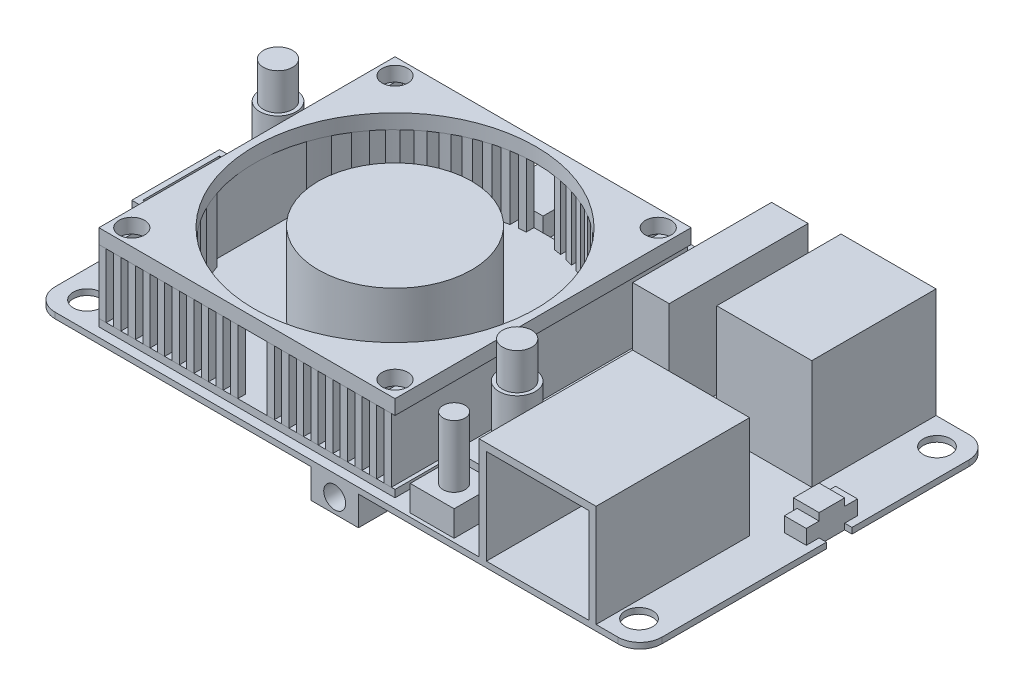
from build123d import *

# Parameters (mm, degrees)
SKETCH1_W                      = 83
SKETCH1_H                      = 48
SKETCH1_R                      = 1.875
BOSS_EXTRUDE1_DEPTH            = 0.8
FILLET1_R                      = 3
BOSS_EXTRUDE2_START            = 11
SKETCH2_R                      = 1.75
SKETCH2_R_2                    = 19.25
BOSS_EXTRUDE2_DEPTH            = 2
SKETCH2_3_W                    = 13
SKETCH2_3_H                    = 17
BOSS_EXTRUDE3_DEPTH            = 15
SKETCH2_4_W                    = 16
SKETCH2_4_H                    = 21
BOSS_EXTRUDE4_DEPTH            = 14
SKETCH2_5_W                    = 5
SKETCH2_5_H                    = 19
BOSS_EXTRUDE5_DEPTH            = 14
SKETCH2_6_R                    = 1.5
BOSS_EXTRUDE6_DEPTH            = 12
SKETCH2_7_W                    = 6
SKETCH2_7_H                    = 6
SKETCH2_7_R                    = 1.5
BOSS_EXTRUDE7_DEPTH            = 3.5
SKETCH2_8_W                    = 7
SKETCH2_8_H                    = 4.25
SKETCH2_8_H_2                  = 0.75
BOSS_EXTRUDE8_DEPTH            = 2.5
SKETCH2_9_W                    = 6.5
SKETCH2_9_H                    = 6.25
SKETCH2_9_H_2                  = 0.75
BOSS_EXTRUDE9_DEPTH            = 3
SKETCH2_10_W                   = 5
SKETCH2_10_H                   = 7.5
BOSS_EXTRUDE10_DEPTH           = 3.5
BOSS_EXTRUDE11_START           = 1.25
BOSS_EXTRUDE11_DEPTH           = 1
BOSS_EXTRUDE12_START           = 2.25
SKETCH2_12_R                   = 2.5
SKETCH2_12_R_2                 = 2
BOSS_EXTRUDE12_DEPTH           = 9
BOSS_EXTRUDE14_START           = 2.25
SKETCH2_13_R                   = 2
BOSS_EXTRUDE14_DEPTH           = 14
BOSS_EXTRUDE15_DEPTH           = 3
SKETCH2_15_W                   = 1
SKETCH2_15_H                   = 3.5
CUT_EXTRUDE1_DEPTH             = 3
SKETCH2_16_W                   = 3
SKETCH2_16_H                   = 1.75
BOSS_EXTRUDE16_DEPTH           = 2
SKETCH2_17_W                   = 2
SKETCH2_17_H                   = 1.75
BOSS_EXTRUDE17_DEPTH           = 2
BOSS_EXTRUDE18_DEPTH           = 6
SKETCH2_19_W                   = 5.06789321
SKETCH2_19_H                   = 12
BOSS_EXTRUDE19_DEPTH           = 5.5
CHAMFER1_SIZE                  = 1
BOSS_EXTRUDE23_DEPTH           = 8.75
BOSS_EXTRUDE23_2_DEPTH         = 8.75
BOSS_EXTRUDE23_3_DEPTH         = 8.75
BOSS_EXTRUDE23_4_DEPTH         = 8.75
BOSS_EXTRUDE23_5_DEPTH         = 8.75
BOSS_EXTRUDE23_6_DEPTH         = 8.75
BOSS_EXTRUDE23_7_DEPTH         = 8.75
BOSS_EXTRUDE23_8_DEPTH         = 8.75
BOSS_EXTRUDE23_9_DEPTH         = 8.75
BOSS_EXTRUDE23_10_DEPTH        = 8.75
BOSS_EXTRUDE23_11_DEPTH        = 8.75
BOSS_EXTRUDE23_12_DEPTH        = 8.75
BOSS_EXTRUDE23_13_DEPTH        = 8.75
BOSS_EXTRUDE23_14_DEPTH        = 8.75
BOSS_EXTRUDE23_15_DEPTH        = 8.75
BOSS_EXTRUDE23_16_DEPTH        = 8.75
BOSS_EXTRUDE23_17_DEPTH        = 8.75
BOSS_EXTRUDE23_18_DEPTH        = 8.75
BOSS_EXTRUDE23_19_DEPTH        = 8.75
BOSS_EXTRUDE23_20_DEPTH        = 8.75
BOSS_EXTRUDE23_21_DEPTH        = 8.75
BOSS_EXTRUDE23_22_DEPTH        = 8.75
BOSS_EXTRUDE23_23_DEPTH        = 8.75
BOSS_EXTRUDE23_24_DEPTH        = 8.75
BOSS_EXTRUDE23_25_DEPTH        = 8.75
BOSS_EXTRUDE23_26_DEPTH        = 8.75
BOSS_EXTRUDE23_27_DEPTH        = 8.75
BOSS_EXTRUDE23_28_DEPTH        = 8.75
BOSS_EXTRUDE23_29_DEPTH        = 8.75
BOSS_EXTRUDE23_30_DEPTH        = 8.75
BOSS_EXTRUDE23_31_DEPTH        = 8.75
BOSS_EXTRUDE23_32_DEPTH        = 8.75
BOSS_EXTRUDE23_33_DEPTH        = 8.75
BOSS_EXTRUDE23_34_DEPTH        = 8.75
BOSS_EXTRUDE23_35_DEPTH        = 8.75
BOSS_EXTRUDE23_36_DEPTH        = 8.75
BOSS_EXTRUDE24_START           = 2.25
SKETCH2_20_R                   = 10.5
BOSS_EXTRUDE24_DEPTH           = 11
SKETCH4_W                      = 4.5
SKETCH4_H                      = 8.5
BOSS_EXTRUDE25_DEPTH           = 4.5
SKETCH4_3_W                    = 11
SKETCH4_3_H                    = 5
BOSS_EXTRUDE26_DEPTH           = 3
SKETCH4_4_W                    = 11
SKETCH4_4_H                    = 13
BOSS_EXTRUDE27_DEPTH           = 2.5
SKETCH4_5_W                    = 13
SKETCH4_5_H                    = 18
SKETCH4_5_W_2                  = 11
SKETCH4_5_H_2                  = 13
BOSS_EXTRUDE28_DEPTH           = 2
SKETCH4_6_W                    = 6.5
SKETCH4_6_H                    = 13
BOSS_EXTRUDE29_DEPTH           = 4
SKETCH4_7_R                    = 1.5
BOSS_EXTRUDE30_DEPTH           = 4
BOSS_EXTRUDE30_DRAFT           = 5
BOSS_EXTRUDE30_PROFILE_2_DEPTH = 4
BOSS_EXTRUDE30_PROFILE_2_DRAFT = 5
SKETCH4_8_R                    = 1.5
BOSS_EXTRUDE31_DEPTH           = 2
BOSS_EXTRUDE31_DRAFT           = 5
BOSS_EXTRUDE31_PROFILE_2_DEPTH = 2
BOSS_EXTRUDE31_PROFILE_2_DRAFT = 5
SKETCH5_W                      = 14
SKETCH5_H                      = 13
CUT_EXTRUDE2_DEPTH             = 19
SKETCH6_W                      = 11
SKETCH6_H                      = 6
SKETCH6_W_2                    = 4
SKETCH6_H_2                    = 13.5
CUT_EXTRUDE3_DEPTH             = 15
SKETCH7_R                      = 1.5
CUT_EXTRUDE4_DEPTH             = 11
CUT_EXTRUDE5_DEPTH             = 5.5


with BuildPart() as part:
    # Sketch1 → Boss-Extrude1 (new body)
    with BuildSketch(Plane(origin=(0, 0, 0), x_dir=(1, 0, 0), z_dir=(0, 1, 0))):
        with Locations((-41.5, 24)):
            Rectangle(SKETCH1_W, SKETCH1_H)
        with Locations(Location((-79.25, 44.375, 0), (0, 0, 270))):
            Circle(SKETCH1_R, mode=Mode.SUBTRACT)
        with Locations(Location((-79.25, 3.625, 0), (0, 0, 270))):
            Circle(SKETCH1_R, mode=Mode.SUBTRACT)
        with Locations(Location((-3.75, 44.375, 0), (0, 0, 270))):
            Circle(SKETCH1_R, mode=Mode.SUBTRACT)
        with Locations(Location((-3.75, 3.625, 0), (0, 0, 270))):
            Circle(SKETCH1_R, mode=Mode.SUBTRACT)
    extrude(amount=BOSS_EXTRUDE1_DEPTH)

    # Fillet1
    fillet1_edges = [part.edges().sort_by_distance(p)[0] for p in [
        (0, 0.4, 0),
        (-83, 0.4, 0),
        (-83, 0.4, -48),
        (0, 0.4, -48),
    ]]
    fillet(fillet1_edges, radius=FILLET1_R)

    # Sketch2_3 → Boss-Extrude3 (add)
    with BuildSketch(Plane(origin=(0, 0.8, 0), x_dir=(1, 0, 0), z_dir=(0, 1, 0))):
        with Locations((-14, 39.5)):
            Rectangle(SKETCH2_3_W, SKETCH2_3_H)
    extrude(amount=BOSS_EXTRUDE3_DEPTH)

    # Sketch2_4 → Boss-Extrude4 (add)
    with BuildSketch(Plane(origin=(0, 0.8, 0), x_dir=(1, 0, 0), z_dir=(0, 1, 0))):
        with Locations((-14, 10.5)):
            Rectangle(SKETCH2_4_W, SKETCH2_4_H)
    extrude(amount=BOSS_EXTRUDE4_DEPTH)

    # Sketch2_5 → Boss-Extrude5 (add)
    with BuildSketch(Plane(origin=(0, 0.8, 0), x_dir=(1, 0, 0), z_dir=(0, 1, 0))):
        with Locations((-27.5, 38.5)):
            Rectangle(SKETCH2_5_W, SKETCH2_5_H)
    extrude(amount=BOSS_EXTRUDE5_DEPTH)

    # Sketch2_6 → Boss-Extrude6 (add)
    with BuildSketch(Plane(origin=(0, 0.8, 0), x_dir=(1, 0, 0), z_dir=(0, 1, 0))):
        with Locations(Location((-28.917074657, 3.5, 0), (0, 0, 90))):
            Circle(SKETCH2_6_R)
    extrude(amount=BOSS_EXTRUDE6_DEPTH)

    # Sketch2_7 → Boss-Extrude7 (add)
    with BuildSketch(Plane(origin=(0, 0.8, 0), x_dir=(1, 0, 0), z_dir=(0, 1, 0))):
        with Locations((-28.917074657, 3.5)):
            Rectangle(SKETCH2_7_W, SKETCH2_7_H)
        with Locations(Location((-28.917074657, 3.5, 0), (0, 0, 270))):
            Circle(SKETCH2_7_R, mode=Mode.SUBTRACT)
    extrude(amount=BOSS_EXTRUDE7_DEPTH)

    # Sketch2_8 → Boss-Extrude8 (add)
    with BuildSketch(Plane(origin=(0, 0.8, 0), x_dir=(1, 0, 0), z_dir=(0, 1, 0))):
        with Locations((-72, 45.875)):
            Rectangle(SKETCH2_8_W, SKETCH2_8_H)
        with Locations((-72, 48.375)):
            Rectangle(SKETCH2_8_W, SKETCH2_8_H_2)
    extrude(amount=BOSS_EXTRUDE8_DEPTH)

    # Sketch2_9 → Boss-Extrude9 (add)
    with BuildSketch(Plane(origin=(0, 0.8, 0), x_dir=(1, 0, 0), z_dir=(0, 1, 0))):
        with Locations((-58.25, 44.875)):
            Rectangle(SKETCH2_9_W, SKETCH2_9_H)
        with Locations((-58.25, 48.375)):
            Rectangle(SKETCH2_9_W, SKETCH2_9_H_2)
    extrude(amount=BOSS_EXTRUDE9_DEPTH)

    # Sketch2_10 → Boss-Extrude10 (add)
    with BuildSketch(Plane(origin=(0, 0.8, 0), x_dir=(1, 0, 0), z_dir=(0, 1, 0))):
        with Locations((-39.5, 44.25)):
            Rectangle(SKETCH2_10_W, SKETCH2_10_H)
    extrude(amount=BOSS_EXTRUDE10_DEPTH)

    # Sketch2_11 → Boss-Extrude11 (add)
    with BuildSketch(Plane(origin=(0, 0.8, 0), x_dir=(1, 0, 0), z_dir=(0, 1, 0)).offset(BOSS_EXTRUDE11_START)):
        with BuildLine():
            Line((-74, 40.5), (-74, 32.5))
            Line((-74, 32.5), (-78.5, 32.5))
            ThreePointArc((-78.5, 32.5), (-82, 29), (-78.5, 25.5))
            Line((-78.5, 25.5), (-74, 25.5))
            Line((-74, 25.5), (-74, 0))
            Line((-74, 0), (-33.5, 0))
            Line((-33.5, 0), (-33.5, 8.705630347))
            Line((-33.5, 8.705630347), (-29, 8.705630347))
            ThreePointArc((-29, 8.705630347), (-25.5, 12.205630347), (-29, 15.705630347))
            Line((-29, 15.705630347), (-33.5, 15.705630347))
            Line((-33.5, 15.705630347), (-33.5, 40.5))
            Line((-33.5, 40.5), (-74, 40.5))
        make_face()
    extrude(amount=BOSS_EXTRUDE11_DEPTH)

    # Sketch2_12 → Boss-Extrude12 (add)
    with BuildSketch(Plane(origin=(0, 0.8, 0), x_dir=(1, 0, 0), z_dir=(0, 1, 0)).offset(BOSS_EXTRUDE12_START)):
        with Locations(Location((-78.5, 29, 0), (0, 0, 270))):
            Circle(SKETCH2_12_R)
        with Locations(Location((-78.5, 29, 0), (0, 0, 270))):
            Circle(SKETCH2_12_R_2, mode=Mode.SUBTRACT)
        with Locations(Location((-29, 12.205630347, 0), (0, 0, 270))):
            Circle(SKETCH2_12_R)
        with Locations(Location((-29, 12.205630347, 0), (0, 0, 270))):
            Circle(SKETCH2_12_R_2, mode=Mode.SUBTRACT)
    extrude(amount=BOSS_EXTRUDE12_DEPTH)

    # Sketch2_13 → Boss-Extrude14 (add)
    with BuildSketch(Plane(origin=(0, 0.8, 0), x_dir=(1, 0, 0), z_dir=(0, 1, 0)).offset(BOSS_EXTRUDE14_START)):
        with Locations(Location((-78.5, 29, 0), (0, 0, 270))):
            Circle(SKETCH2_13_R)
        with Locations(Location((-29, 12.205630347, 0), (0, 0, 270))):
            Circle(SKETCH2_13_R)
    extrude(amount=BOSS_EXTRUDE14_DEPTH)

    # Sketch2_14 → Boss-Extrude15 (add)
    with BuildSketch(Plane(origin=(0, 0.8, 0), x_dir=(1, 0, 0), z_dir=(0, 1, 0))):
        Polygon((-1, 25.5), (-1, 29), (-4, 29), (-4.5, 29), (-4.5, 25.5), (-4, 25.5), align=None)
    extrude(amount=BOSS_EXTRUDE15_DEPTH)

    # Sketch2_15 → Cut-Extrude1 (cut)
    with BuildSketch(Plane(origin=(0, 0.8, 0), x_dir=(1, 0, 0), z_dir=(0, 1, 0))):
        with Locations((-0.5, 27.25)):
            Rectangle(SKETCH2_15_W, SKETCH2_15_H)
    extrude(amount=-CUT_EXTRUDE1_DEPTH, mode=Mode.SUBTRACT)

    # Sketch2_16 → Boss-Extrude16 (add)
    with BuildSketch(Plane(origin=(0, 0.8, 0), x_dir=(1, 0, 0), z_dir=(0, 1, 0))):
        with Locations((-2.5, 29.875)):
            Rectangle(SKETCH2_16_W, SKETCH2_16_H)
        with Locations((-2.5, 24.625)):
            Rectangle(SKETCH2_16_W, SKETCH2_16_H)
    extrude(amount=BOSS_EXTRUDE16_DEPTH)

    # Sketch2_17 → Boss-Extrude17 (add)
    with BuildSketch(Plane(origin=(0, 0.8, 0), x_dir=(1, 0, 0), z_dir=(0, 1, 0))):
        Polygon((-27, 22), (-27, 20.25), (-29, 20.25), (-29, 27.25), (-27, 27.25), (-27, 25.5), (-26.5, 25.5), (-26.5, 22), align=None)
        with Locations((-28, 21.125)):
            Rectangle(SKETCH2_17_W, SKETCH2_17_H)
        with Locations((-28, 26.375)):
            Rectangle(SKETCH2_17_W, SKETCH2_17_H)
    extrude(amount=BOSS_EXTRUDE17_DEPTH)

    # Sketch2_18 → Boss-Extrude18 (add)
    with BuildSketch(Plane(origin=(0, 0.8, 0), x_dir=(1, 0, 0), z_dir=(0, 1, 0))):
        Polygon((-27, 25.5), (-29, 25.5), (-29, 22), (-27, 22), (-26.5, 22), (-26.5, 25.5), align=None)
    extrude(amount=BOSS_EXTRUDE18_DEPTH)

    # Sketch2_19 → Boss-Extrude19 (add)
    with BuildSketch(Plane(origin=(0, 0.8, 0), x_dir=(1, 0, 0), z_dir=(0, 1, 0))):
        with Locations((-79.966053395, 19)):
            Rectangle(SKETCH2_19_W, SKETCH2_19_H)
    extrude(amount=BOSS_EXTRUDE19_DEPTH)

    # Chamfer1
    chamfer1_edges = [part.edges().sort_by_distance(p)[0] for p in [
        (-77.43210679, 3.55, -25),
    ]]
    chamfer(chamfer1_edges, length=CHAMFER1_SIZE)

    # Sketch2_20 → Boss-Extrude24 (add)
    with BuildSketch(Plane(origin=(0, 0.8, 0), x_dir=(1, 0, 0), z_dir=(0, 1, 0)).offset(BOSS_EXTRUDE24_START)):
        with Locations(Location((-53.75, 20.25, 0), (0, 0, 270))):
            Circle(SKETCH2_20_R)
    extrude(amount=BOSS_EXTRUDE24_DEPTH)

    # Sketch4 → Boss-Extrude25 (add)
    with BuildSketch(Plane.XZ):
        with Locations((-80.25, -36.75)):
            Rectangle(SKETCH4_W, SKETCH4_H)
    extrude(amount=BOSS_EXTRUDE25_DEPTH)

    # Sketch4_3 → Boss-Extrude26 (add)
    with BuildSketch(Plane.XZ):
        with Locations((-69, -12.5)):
            Rectangle(SKETCH4_3_W, SKETCH4_3_H)
    extrude(amount=BOSS_EXTRUDE26_DEPTH)

    # Sketch4_4 → Boss-Extrude27 (add)
    with BuildSketch(Plane.XZ):
        with Locations((-56.5, -10)):
            Rectangle(SKETCH4_4_W, SKETCH4_4_H)
    extrude(amount=BOSS_EXTRUDE27_DEPTH)

    # Sketch4_5 → Boss-Extrude28 (add)
    with BuildSketch(Plane.XZ):
        with Locations((-56.5, -11)):
            Rectangle(SKETCH4_5_W, SKETCH4_5_H)
        with Locations((-56.5, -10)):
            Rectangle(SKETCH4_5_W_2, SKETCH4_5_H_2, mode=Mode.SUBTRACT)
    extrude(amount=BOSS_EXTRUDE28_DEPTH)

    # Sketch4_6 → Boss-Extrude29 (add)
    with BuildSketch(Plane.XZ):
        with Locations((-41.75, -6.5)):
            Rectangle(SKETCH4_6_W, SKETCH4_6_H)
    extrude(amount=BOSS_EXTRUDE29_DEPTH)


with BuildPart() as body_2:
    # Sketch2 → Boss-Extrude2 (new body)
    with BuildSketch(Plane(origin=(0, 0.8, 0), x_dir=(1, 0, 0), z_dir=(0, 1, 0)).offset(BOSS_EXTRUDE2_START)):
        Polygon((-42, 40.5), (-74, 40.5), (-74, 32.5), (-74, 25.5), (-74, 0), (-33.5, 0), (-33.5, 8.705630347), (-33.5, 15.705630347), (-33.5, 40.5), (-37, 40.5), align=None)
        with Locations(Location((-71.75, 2.25, 0), (0, 0, 270))):
            Circle(SKETCH2_R, mode=Mode.SUBTRACT)
        with Locations(Location((-53.75, 20.25, 0), (0, 0, 270))):
            Circle(SKETCH2_R_2, mode=Mode.SUBTRACT)
        with Locations(Location((-35.75, 2.25, 0), (0, 0, 270))):
            Circle(SKETCH2_R, mode=Mode.SUBTRACT)
        with Locations(Location((-71.75, 38.25, 0), (0, 0, 270))):
            Circle(SKETCH2_R, mode=Mode.SUBTRACT)
        with Locations(Location((-35.75, 38.25, 0), (0, 0, 270))):
            Circle(SKETCH2_R, mode=Mode.SUBTRACT)
    extrude(amount=BOSS_EXTRUDE2_DEPTH)


with BuildPart() as body_3:
    # Sketch3 → Boss-Extrude23 (new body)
    with BuildSketch(Plane(origin=(0, 3.05, 0), x_dir=(1, 0, 0), z_dir=(0, 1, 0))):
        Polygon((-74, 40.5), (-74, 32.5), (-74, 25.5), (-74, 0), (-73, 0), (-73, 20.25), (-73, 25.5), (-73, 32.5), (-73, 40.5), align=None)
    extrude(amount=BOSS_EXTRUDE23_DEPTH)


with BuildPart() as body_4:
    # Sketch3 → Boss-Extrude23 2 (new body)
    with BuildSketch(Plane(origin=(0, 3.05, 0), x_dir=(1, 0, 0), z_dir=(0, 1, 0))):
        with BuildLine():
            Line((-72, 14.126275643), (-72, 0))
            Line((-72, 0), (-71, 0))
            Line((-71, 0), (-71, 11.705996255))
            ThreePointArc((-71, 11.705996255), (-71.541203952, 12.899111488), (-72, 14.126275643))
        make_face()
    extrude(amount=BOSS_EXTRUDE23_2_DEPTH)


with BuildPart() as body_5:
    # Sketch3 → Boss-Extrude23 3 (new body)
    with BuildSketch(Plane(origin=(0, 3.05, 0), x_dir=(1, 0, 0), z_dir=(0, 1, 0))):
        with BuildLine():
            Line((-70, 9.93011628), (-70, 0))
            Line((-70, 0), (-69, 0))
            Line((-69, 0), (-69, 8.502659876))
            ThreePointArc((-69, 8.502659876), (-69.516163387, 9.205064869), (-70, 9.93011628))
        make_face()
    extrude(amount=BOSS_EXTRUDE23_3_DEPTH)


with BuildPart() as body_6:
    # Sketch3 → Boss-Extrude23 4 (new body)
    with BuildSketch(Plane(origin=(0, 3.05, 0), x_dir=(1, 0, 0), z_dir=(0, 1, 0))):
        with BuildLine():
            Line((-68, 7.307820894), (-68, 0))
            Line((-68, 0), (-67, 0))
            Line((-67, 0), (-67, 6.285759956))
            ThreePointArc((-67, 6.285759956), (-67.509493164, 6.787502169), (-68, 7.307820894))
        make_face()
    extrude(amount=BOSS_EXTRUDE23_4_DEPTH)


with BuildPart() as body_7:
    # Sketch3 → Boss-Extrude23 5 (new body)
    with BuildSketch(Plane(origin=(0, 3.05, 0), x_dir=(1, 0, 0), z_dir=(0, 1, 0))):
        with BuildLine():
            Line((-66, 5.400757595), (-66, 0))
            Line((-66, 0), (-65, 0))
            Line((-65, 0), (-65, 4.629500648))
            ThreePointArc((-65, 4.629500648), (-65.506326353, 5.006926469), (-66, 5.400757595))
        make_face()
    extrude(amount=BOSS_EXTRUDE23_5_DEPTH)


with BuildPart() as body_8:
    # Sketch3 → Boss-Extrude23 6 (new body)
    with BuildSketch(Plane(origin=(0, 3.05, 0), x_dir=(1, 0, 0), z_dir=(0, 1, 0))):
        with BuildLine():
            Line((-64, 3.955829263), (-64, 0))
            Line((-64, 0), (-63, 0))
            Line((-63, 0), (-63, 3.368056984))
            ThreePointArc((-63, 3.368056984), (-63.504428177, 3.654409292), (-64, 3.955829263))
        make_face()
    extrude(amount=BOSS_EXTRUDE23_6_DEPTH)


with BuildPart() as body_9:
    # Sketch3 → Boss-Extrude23 7 (new body)
    with BuildSketch(Plane(origin=(0, 3.05, 0), x_dir=(1, 0, 0), z_dir=(0, 1, 0))):
        with BuildLine():
            Line((-62, 2.857472869), (-62, 0))
            Line((-62, 0), (-61, 0))
            Line((-61, 0), (-61, 2.4174455))
            ThreePointArc((-61, 2.4174455), (-61.50312234, 2.630363398), (-62, 2.857472869))
        make_face()
    extrude(amount=BOSS_EXTRUDE23_7_DEPTH)


with BuildPart() as body_10:
    # Sketch3 → Boss-Extrude23 8 (new body)
    with BuildSketch(Plane(origin=(0, 3.05, 0), x_dir=(1, 0, 0), z_dir=(0, 1, 0))):
        with BuildLine():
            Line((-60, 2.042858544), (-60, 0))
            Line((-60, 0), (-59, 0))
            Line((-59, 0), (-59, 1.729740823))
            ThreePointArc((-59, 1.729740823), (-59.502130968, 1.879494037), (-60, 2.042858544))
        make_face()
    extrude(amount=BOSS_EXTRUDE23_8_DEPTH)


with BuildPart() as body_11:
    # Sketch3 → Boss-Extrude23 9 (new body)
    with BuildSketch(Plane(origin=(0, 3.05, 0), x_dir=(1, 0, 0), z_dir=(0, 1, 0))):
        with BuildLine():
            Line((-58, 1.475016644), (-58, 0))
            Line((-58, 0), (-57, 0))
            Line((-57, 0), (-57, 1.276334039))
            ThreePointArc((-57, 1.276334039), (-57.501315595, 1.36905375), (-58, 1.475016644))
        make_face()
    extrude(amount=BOSS_EXTRUDE23_9_DEPTH)


with BuildPart() as body_12:
    # Sketch3 → Boss-Extrude23 10 (new body)
    with BuildSketch(Plane(origin=(0, 3.05, 0), x_dir=(1, 0, 0), z_dir=(0, 1, 0))):
        with BuildLine():
            Line((-56, 1.131945706), (-56, 0))
            Line((-56, 0), (-55, 0))
            Line((-55, 0), (-55, 1.040627288))
            ThreePointArc((-55, 1.040627288), (-55.500595545, 1.079764862), (-56, 1.131945706))
        make_face()
    extrude(amount=BOSS_EXTRUDE23_10_DEPTH)


with BuildPart() as body_13:
    # Sketch3 → Boss-Extrude23 11 (new body)
    with BuildSketch(Plane(origin=(0, 3.05, 0), x_dir=(1, 0, 0), z_dir=(0, 1, 0))):
        with BuildLine():
            Line((-71, 40.5), (-72, 40.5))
            Line((-72, 40.5), (-72, 32.5))
            Line((-72, 32.5), (-72, 26.373724357))
            ThreePointArc((-72, 26.373724357), (-71.541203952, 27.600888512), (-71, 28.794003745))
            Line((-71, 28.794003745), (-71, 32.5))
            Line((-71, 32.5), (-71, 40.5))
        make_face()
    extrude(amount=BOSS_EXTRUDE23_11_DEPTH)


with BuildPart() as body_14:
    # Sketch3 → Boss-Extrude23 12 (new body)
    with BuildSketch(Plane(origin=(0, 3.05, 0), x_dir=(1, 0, 0), z_dir=(0, 1, 0))):
        with BuildLine():
            Line((-69, 40.5), (-70, 40.5))
            Line((-70, 40.5), (-70, 32.5))
            Line((-70, 32.5), (-70, 30.56988372))
            ThreePointArc((-70, 30.56988372), (-69.516163387, 31.294935131), (-69, 31.997340124))
            Line((-69, 31.997340124), (-69, 32.5))
            Line((-69, 32.5), (-69, 40.5))
        make_face()
    extrude(amount=BOSS_EXTRUDE23_12_DEPTH)


with BuildPart() as body_15:
    # Sketch3 → Boss-Extrude23 13 (new body)
    with BuildSketch(Plane(origin=(0, 3.05, 0), x_dir=(1, 0, 0), z_dir=(0, 1, 0))):
        with BuildLine():
            Line((-67, 40.5), (-68, 40.5))
            Line((-68, 40.5), (-68, 33.192179106))
            ThreePointArc((-68, 33.192179106), (-67.509493164, 33.712497831), (-67, 34.214240044))
            Line((-67, 34.214240044), (-67, 40.5))
        make_face()
    extrude(amount=BOSS_EXTRUDE23_13_DEPTH)


with BuildPart() as body_16:
    # Sketch3 → Boss-Extrude23 14 (new body)
    with BuildSketch(Plane(origin=(0, 3.05, 0), x_dir=(1, 0, 0), z_dir=(0, 1, 0))):
        with BuildLine():
            Line((-65, 40.5), (-66, 40.5))
            Line((-66, 40.5), (-66, 35.099242405))
            ThreePointArc((-66, 35.099242405), (-65.506326353, 35.493073531), (-65, 35.870499352))
            Line((-65, 35.870499352), (-65, 40.5))
        make_face()
    extrude(amount=BOSS_EXTRUDE23_14_DEPTH)


with BuildPart() as body_17:
    # Sketch3 → Boss-Extrude23 15 (new body)
    with BuildSketch(Plane(origin=(0, 3.05, 0), x_dir=(1, 0, 0), z_dir=(0, 1, 0))):
        with BuildLine():
            Line((-63, 40.5), (-64, 40.5))
            Line((-64, 40.5), (-64, 36.544170737))
            ThreePointArc((-64, 36.544170737), (-63.504428177, 36.845590708), (-63, 37.131943016))
            Line((-63, 37.131943016), (-63, 40.5))
        make_face()
    extrude(amount=BOSS_EXTRUDE23_15_DEPTH)


with BuildPart() as body_18:
    # Sketch3 → Boss-Extrude23 16 (new body)
    with BuildSketch(Plane(origin=(0, 3.05, 0), x_dir=(1, 0, 0), z_dir=(0, 1, 0))):
        with BuildLine():
            Line((-61, 40.5), (-62, 40.5))
            Line((-62, 40.5), (-62, 37.642527131))
            ThreePointArc((-62, 37.642527131), (-61.50312234, 37.869636602), (-61, 38.0825545))
            Line((-61, 38.0825545), (-61, 40.5))
        make_face()
    extrude(amount=BOSS_EXTRUDE23_16_DEPTH)


with BuildPart() as body_19:
    # Sketch3 → Boss-Extrude23 17 (new body)
    with BuildSketch(Plane(origin=(0, 3.05, 0), x_dir=(1, 0, 0), z_dir=(0, 1, 0))):
        with BuildLine():
            Line((-59, 40.5), (-60, 40.5))
            Line((-60, 40.5), (-60, 38.457141456))
            ThreePointArc((-60, 38.457141456), (-59.502130968, 38.620505963), (-59, 38.770259177))
            Line((-59, 38.770259177), (-59, 40.5))
        make_face()
    extrude(amount=BOSS_EXTRUDE23_17_DEPTH)


with BuildPart() as body_20:
    # Sketch3 → Boss-Extrude23 18 (new body)
    with BuildSketch(Plane(origin=(0, 3.05, 0), x_dir=(1, 0, 0), z_dir=(0, 1, 0))):
        with BuildLine():
            Line((-57, 40.5), (-58, 40.5))
            Line((-58, 40.5), (-58, 39.024983356))
            ThreePointArc((-58, 39.024983356), (-57.501315595, 39.13094625), (-57, 39.223665961))
            Line((-57, 39.223665961), (-57, 40.5))
        make_face()
    extrude(amount=BOSS_EXTRUDE23_18_DEPTH)


with BuildPart() as body_21:
    # Sketch3 → Boss-Extrude23 19 (new body)
    with BuildSketch(Plane(origin=(0, 3.05, 0), x_dir=(1, 0, 0), z_dir=(0, 1, 0))):
        with BuildLine():
            Line((-55, 40.5), (-56, 40.5))
            Line((-56, 40.5), (-56, 39.368054294))
            ThreePointArc((-56, 39.368054294), (-55.500595545, 39.420235138), (-55, 39.459372712))
            Line((-55, 39.459372712), (-55, 40.5))
        make_face()
    extrude(amount=BOSS_EXTRUDE23_19_DEPTH)


with BuildPart() as body_22:
    # Sketch3 → Boss-Extrude23 20 (new body)
    with BuildSketch(Plane(origin=(0, 3.05, 0), x_dir=(1, 0, 0), z_dir=(0, 1, 0))):
        with BuildLine():
            Line((-51, 1.197441117), (-51, 0))
            Line((-51, 0), (-50, 0))
            Line((-50, 0), (-50, 1.368792412))
            ThreePointArc((-50, 1.368792412), (-50.498870917, 1.276527474), (-51, 1.197441117))
        make_face()
    extrude(amount=BOSS_EXTRUDE23_20_DEPTH)


with BuildPart() as body_23:
    # Sketch3 → Boss-Extrude23 21 (new body)
    with BuildSketch(Plane(origin=(0, 3.05, 0), x_dir=(1, 0, 0), z_dir=(0, 1, 0))):
        with BuildLine():
            Line((-49, 1.595241894), (-49, 0))
            Line((-49, 0), (-48, 0))
            Line((-48, 0), (-48, 1.878826929))
            ThreePointArc((-48, 1.878826929), (-48.498085576, 1.730283618), (-49, 1.595241894))
        make_face()
    extrude(amount=BOSS_EXTRUDE23_21_DEPTH)


with BuildPart() as body_24:
    # Sketch3 → Boss-Extrude23 22 (new body)
    with BuildSketch(Plane(origin=(0, 3.05, 0), x_dir=(1, 0, 0), z_dir=(0, 1, 0))):
        with BuildLine():
            Line((-47, 2.222243623), (-47, 0))
            Line((-47, 0), (-46, 0))
            Line((-46, 0), (-46, 2.628989813))
            ThreePointArc((-46, 2.628989813), (-46.497148105, 2.418605232), (-47, 2.222243623))
        make_face()
    extrude(amount=BOSS_EXTRUDE23_22_DEPTH)


with BuildPart() as body_25:
    # Sketch3 → Boss-Extrude23 23 (new body)
    with BuildSketch(Plane(origin=(0, 3.05, 0), x_dir=(1, 0, 0), z_dir=(0, 1, 0))):
        with BuildLine():
            Line((-45, 3.103571801), (-45, 0))
            Line((-45, 0), (-44, 0))
            Line((-44, 0), (-44, 3.651807327))
            ThreePointArc((-44, 3.651807327), (-44.49593924, 3.370282602), (-45, 3.103571801))
        make_face()
    extrude(amount=BOSS_EXTRUDE23_23_DEPTH)


with BuildPart() as body_26:
    # Sketch3 → Boss-Extrude23 24 (new body)
    with BuildSketch(Plane(origin=(0, 3.05, 0), x_dir=(1, 0, 0), z_dir=(0, 1, 0))):
        with BuildLine():
            Line((-43, 4.281280577), (-43, 0))
            Line((-43, 0), (-42, 0))
            Line((-42, 0), (-42, 5.002049318))
            ThreePointArc((-42, 5.002049318), (-42.494229174, 4.63365846), (-43, 4.281280577))
        make_face()
    extrude(amount=BOSS_EXTRUDE23_24_DEPTH)


with BuildPart() as body_27:
    # Sketch3 → Boss-Extrude23 25 (new body)
    with BuildSketch(Plane(origin=(0, 3.05, 0), x_dir=(1, 0, 0), z_dir=(0, 1, 0))):
        with BuildLine():
            Line((-41, 5.827794898), (-41, 0))
            Line((-41, 0), (-40, 0))
            Line((-40, 0), (-40, 6.777806415))
            ThreePointArc((-40, 6.777806415), (-40.491488377, 6.293841161), (-41, 5.827794898))
        make_face()
    extrude(amount=BOSS_EXTRUDE23_25_DEPTH)


with BuildPart() as body_28:
    # Sketch3 → Boss-Extrude23 26 (new body)
    with BuildSketch(Plane(origin=(0, 3.05, 0), x_dir=(1, 0, 0), z_dir=(0, 1, 0))):
        with BuildLine():
            Line((-39, 7.880683123), (-39, 0))
            Line((-39, 0), (-38, 0))
            Line((-38, 0), (-38, 9.182028189))
            ThreePointArc((-38, 9.182028189), (-38.486125173, 8.520693744), (-39, 7.880683123))
        make_face()
    extrude(amount=BOSS_EXTRUDE23_26_DEPTH)


with BuildPart() as body_29:
    # Sketch3 → Boss-Extrude23 27 (new body)
    with BuildSketch(Plane(origin=(0, 3.05, 0), x_dir=(1, 0, 0), z_dir=(0, 1, 0))):
        with BuildLine():
            Line((-37, 10.763167019), (-37, 0))
            Line((-37, 0), (-36, 0))
            Line((-36, 0), (-36, 12.800167787))
            ThreePointArc((-36, 12.800167787), (-36.469958246, 11.76691937), (-37, 10.763167019))
        make_face()
    extrude(amount=BOSS_EXTRUDE23_27_DEPTH)


with BuildPart() as body_30:
    # Sketch3 → Boss-Extrude23 28 (new body)
    with BuildSketch(Plane(origin=(0, 3.05, 0), x_dir=(1, 0, 0), z_dir=(0, 1, 0))):
        with BuildLine():
            Line((-34, 40.5), (-35, 40.5))
            Line((-35, 40.5), (-35, 32.5))
            Line((-35, 32.5), (-35, 25.5))
            Line((-35, 25.5), (-35, 24.608898944))
            ThreePointArc((-35, 24.608898944), (-34.625408501, 22.443741097), (-34.5, 20.25))
            ThreePointArc((-34.5, 20.25), (-34.625408501, 18.056258903), (-35, 15.891101056))
            Line((-35, 15.891101056), (-35, 0))
            Line((-35, 0), (-34, 0))
            Line((-34, 0), (-34, 25.5))
            Line((-34, 25.5), (-34, 32.5))
            Line((-34, 32.5), (-34, 40.5))
        make_face()
    extrude(amount=BOSS_EXTRUDE23_28_DEPTH)


with BuildPart() as body_31:
    # Sketch3 → Boss-Extrude23 29 (new body)
    with BuildSketch(Plane(origin=(0, 3.05, 0), x_dir=(1, 0, 0), z_dir=(0, 1, 0))):
        with BuildLine():
            Line((-36, 40.5), (-37, 40.5))
            Line((-37, 40.5), (-37, 32.5))
            Line((-37, 32.5), (-37, 29.736832981))
            ThreePointArc((-37, 29.736832981), (-36.469958246, 28.73308063), (-36, 27.699832213))
            Line((-36, 27.699832213), (-36, 32.5))
            Line((-36, 32.5), (-36, 40.5))
        make_face()
    extrude(amount=BOSS_EXTRUDE23_29_DEPTH)


with BuildPart() as body_32:
    # Sketch3 → Boss-Extrude23 30 (new body)
    with BuildSketch(Plane(origin=(0, 3.05, 0), x_dir=(1, 0, 0), z_dir=(0, 1, 0))):
        with BuildLine():
            Line((-38, 40.5), (-39, 40.5))
            Line((-39, 40.5), (-39, 32.619316877))
            ThreePointArc((-39, 32.619316877), (-38.486125173, 31.979306256), (-38, 31.317971811))
            Line((-38, 31.317971811), (-38, 32.5))
            Line((-38, 32.5), (-38, 40.5))
        make_face()
    extrude(amount=BOSS_EXTRUDE23_30_DEPTH)


with BuildPart() as body_33:
    # Sketch3 → Boss-Extrude23 31 (new body)
    with BuildSketch(Plane(origin=(0, 3.05, 0), x_dir=(1, 0, 0), z_dir=(0, 1, 0))):
        with BuildLine():
            Line((-40, 40.5), (-41, 40.5))
            Line((-41, 40.5), (-41, 34.672205102))
            ThreePointArc((-41, 34.672205102), (-40.491488377, 34.206158839), (-40, 33.722193585))
            Line((-40, 33.722193585), (-40, 40.5))
        make_face()
    extrude(amount=BOSS_EXTRUDE23_31_DEPTH)


with BuildPart() as body_34:
    # Sketch3 → Boss-Extrude23 32 (new body)
    with BuildSketch(Plane(origin=(0, 3.05, 0), x_dir=(1, 0, 0), z_dir=(0, 1, 0))):
        with BuildLine():
            Line((-42, 40.5), (-43, 40.5))
            Line((-43, 40.5), (-43, 36.218719423))
            ThreePointArc((-43, 36.218719423), (-42.494229174, 35.86634154), (-42, 35.497950682))
            Line((-42, 35.497950682), (-42, 40.5))
        make_face()
    extrude(amount=BOSS_EXTRUDE23_32_DEPTH)


with BuildPart() as body_35:
    # Sketch3 → Boss-Extrude23 33 (new body)
    with BuildSketch(Plane(origin=(0, 3.05, 0), x_dir=(1, 0, 0), z_dir=(0, 1, 0))):
        with BuildLine():
            Line((-44, 40.5), (-45, 40.5))
            Line((-45, 40.5), (-45, 37.396428199))
            ThreePointArc((-45, 37.396428199), (-44.49593924, 37.129717398), (-44, 36.848192673))
            Line((-44, 36.848192673), (-44, 40.5))
        make_face()
    extrude(amount=BOSS_EXTRUDE23_33_DEPTH)


with BuildPart() as body_36:
    # Sketch3 → Boss-Extrude23 34 (new body)
    with BuildSketch(Plane(origin=(0, 3.05, 0), x_dir=(1, 0, 0), z_dir=(0, 1, 0))):
        with BuildLine():
            Line((-46, 40.5), (-47, 40.5))
            Line((-47, 40.5), (-47, 38.277756377))
            ThreePointArc((-47, 38.277756377), (-46.497148105, 38.081394768), (-46, 37.871010187))
            Line((-46, 37.871010187), (-46, 40.5))
        make_face()
    extrude(amount=BOSS_EXTRUDE23_34_DEPTH)


with BuildPart() as body_37:
    # Sketch3 → Boss-Extrude23 35 (new body)
    with BuildSketch(Plane(origin=(0, 3.05, 0), x_dir=(1, 0, 0), z_dir=(0, 1, 0))):
        with BuildLine():
            Line((-48, 40.5), (-49, 40.5))
            Line((-49, 40.5), (-49, 38.904758106))
            ThreePointArc((-49, 38.904758106), (-48.498085576, 38.769716382), (-48, 38.621173071))
            Line((-48, 38.621173071), (-48, 40.5))
        make_face()
    extrude(amount=BOSS_EXTRUDE23_35_DEPTH)


with BuildPart() as body_38:
    # Sketch3 → Boss-Extrude23 36 (new body)
    with BuildSketch(Plane(origin=(0, 3.05, 0), x_dir=(1, 0, 0), z_dir=(0, 1, 0))):
        with BuildLine():
            Line((-50, 40.5), (-51, 40.5))
            Line((-51, 40.5), (-51, 39.302558883))
            ThreePointArc((-51, 39.302558883), (-50.498870917, 39.223472526), (-50, 39.131207588))
            Line((-50, 39.131207588), (-50, 40.5))
        make_face()
    extrude(amount=BOSS_EXTRUDE23_36_DEPTH)


with BuildPart() as boss_extrude30_tool:
    # Sketch4_7 → Boss-Extrude30 (with draft: the straight prism first)
    with BuildSketch(Plane.XZ):
        with Locations((-78.5, -29)):
            Circle(SKETCH4_7_R)
    extrude(amount=BOSS_EXTRUDE30_DEPTH)
    # Boss-Extrude30: the draft: its side faces are tilted about the plane it starts from
    boss_extrude30_sides = [boss_extrude30_tool.faces().sort_by_distance(p)[0] for p in [
        (-80, -2, -29),
    ]]
    draft(boss_extrude30_sides, Plane.XZ, BOSS_EXTRUDE30_DRAFT)


with BuildPart() as part_1:
    add(part.part)

    # Boss-Extrude30: add boss_extrude30_tool
    add(boss_extrude30_tool.part)


with BuildPart() as boss_extrude30_profile_2_tool:
    # Sketch4_7 → Boss-Extrude30 profile 2 (with draft: the straight prism first)
    with BuildSketch(Plane.XZ):
        with Locations((-29, -12.205630347)):
            Circle(SKETCH4_7_R)
    extrude(amount=BOSS_EXTRUDE30_PROFILE_2_DEPTH)
    # Boss-Extrude30 profile 2: the draft: its side faces are tilted about the plane it starts from
    boss_extrude30_profile_2_sides = [boss_extrude30_profile_2_tool.faces().sort_by_distance(p)[0] for p in [
        (-30.5, -2, -12.205630347),
    ]]
    draft(boss_extrude30_profile_2_sides, Plane.XZ, BOSS_EXTRUDE30_PROFILE_2_DRAFT)


with BuildPart() as part_2:
    add(part_1.part)

    # Boss-Extrude30 profile 2: add boss_extrude30_profile_2_tool
    add(boss_extrude30_profile_2_tool.part)


with BuildPart() as boss_extrude31_tool:
    # Sketch4_8 → Boss-Extrude31 (with draft: the straight prism first)
    with BuildSketch(Plane.XZ):
        with Locations((-20.25, -10)):
            Circle(SKETCH4_8_R)
    extrude(amount=BOSS_EXTRUDE31_DEPTH)
    # Boss-Extrude31: the draft: its side faces are tilted about the plane it starts from
    boss_extrude31_sides = [boss_extrude31_tool.faces().sort_by_distance(p)[0] for p in [
        (-21.75, -1, -10),
    ]]
    draft(boss_extrude31_sides, Plane.XZ, BOSS_EXTRUDE31_DRAFT)


with BuildPart() as part_3:
    add(part_2.part)

    # Boss-Extrude31: add boss_extrude31_tool
    add(boss_extrude31_tool.part)


with BuildPart() as boss_extrude31_profile_2_tool:
    # Sketch4_8 → Boss-Extrude31 profile 2 (with draft: the straight prism first)
    with BuildSketch(Plane.XZ):
        with Locations((-7.75, -10)):
            Circle(SKETCH4_8_R)
    extrude(amount=BOSS_EXTRUDE31_PROFILE_2_DEPTH)
    # Boss-Extrude31 profile 2: the draft: its side faces are tilted about the plane it starts from
    boss_extrude31_profile_2_sides = [boss_extrude31_profile_2_tool.faces().sort_by_distance(p)[0] for p in [
        (-9.25, -1, -10),
    ]]
    draft(boss_extrude31_profile_2_sides, Plane.XZ, BOSS_EXTRUDE31_PROFILE_2_DRAFT)


with BuildPart() as part_4:
    add(part_3.part)

    # Boss-Extrude31 profile 2: add boss_extrude31_profile_2_tool
    add(boss_extrude31_profile_2_tool.part)

    # Sketch5 → Cut-Extrude2 (cut)
    with BuildSketch(Plane.XY):
        with Locations((-14, 7.3)):
            Rectangle(SKETCH5_W, SKETCH5_H)
    extrude(amount=-CUT_EXTRUDE2_DEPTH, mode=Mode.SUBTRACT)

    # Sketch6 → Cut-Extrude3 (cut)
    with BuildSketch(Plane(origin=(0, 0, -48), x_dir=(-1, 0, 0), z_dir=(0, 0, -1))):
        with Locations((14, 11.8)):
            Rectangle(SKETCH6_W, SKETCH6_H)
        with Locations((14, 3.8)):
            Rectangle(SKETCH6_W, SKETCH6_H)
        with Locations((27.5, 7.55)):
            Rectangle(SKETCH6_W_2, SKETCH6_H_2)
    extrude(amount=-CUT_EXTRUDE3_DEPTH, mode=Mode.SUBTRACT)

    # Sketch7 → Cut-Extrude4 (cut)
    with BuildSketch(Plane.XY):
        with Locations((-41.75, -2)):
            Circle(SKETCH7_R)
    extrude(amount=-CUT_EXTRUDE4_DEPTH, mode=Mode.SUBTRACT)

    # Sketch8 → Cut-Extrude5 (cut)
    with BuildSketch(Plane(origin=(0, 6.3, 0), x_dir=(1, 0, 0), z_dir=(0, 1, 0))):
        Polygon((-78.18210679, 13.75), (-78.18210679, 23.689339828), (-78.742766962, 24.25), (-81.75, 24.25), (-81.75, 13.75), align=None)
    extrude(amount=-CUT_EXTRUDE5_DEPTH, mode=Mode.SUBTRACT)


solid = Compound([body_2.part, body_3.part, body_4.part, body_5.part, body_6.part, body_7.part, body_8.part, body_9.part, body_10.part, body_11.part, body_12.part, body_13.part, body_14.part, body_15.part, body_16.part, body_17.part, body_18.part, body_19.part, body_20.part, body_21.part, body_22.part, body_23.part, body_24.part, body_25.part, body_26.part, body_27.part, body_28.part, body_29.part, body_30.part, body_31.part, body_32.part, body_33.part, body_34.part, body_35.part, body_36.part, body_37.part, body_38.part, part_4.part])
